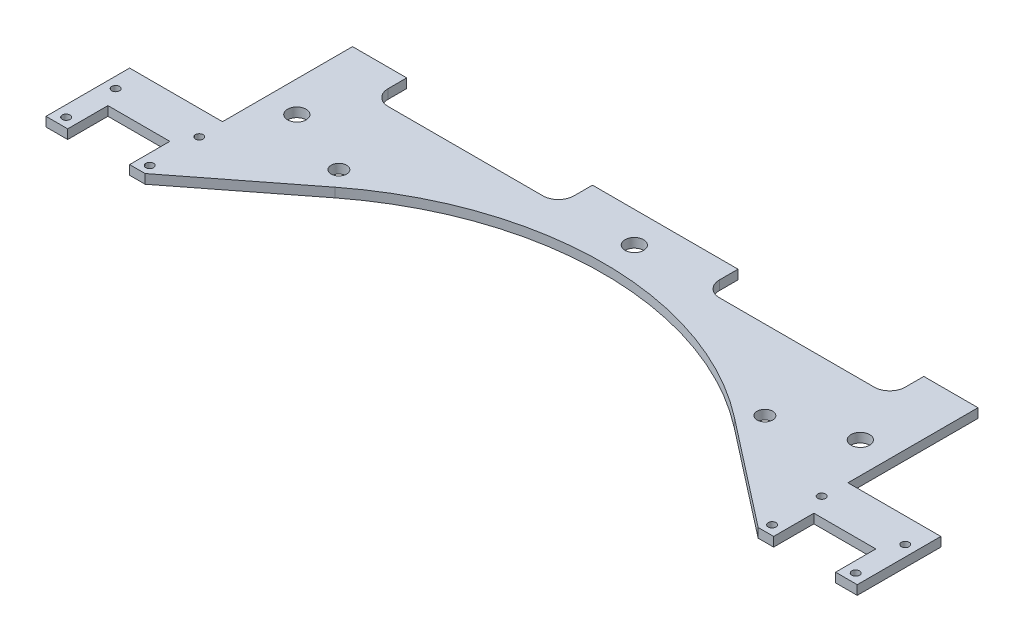
from build123d import *

# Parameters (mm, degrees)
ESQUISSE1_R      = 3
ESQUISSE1_R_2    = 1.25
ESQUISSE1_R_3    = 2.5
EXTRUSION1_DEPTH = 3


with BuildPart() as part:
    # Esquisse1 → Extrusion1 (new body)
    with BuildSketch(Plane(origin=(0, 0, 0), x_dir=(1, 0, 0), z_dir=(0, 1, 0))):
        with BuildLine():
            Line((-64.494367887, 52.858171056), (-99, 26))
            Line((-99, 26), (-104, 26))
            Line((-104, 26), (-104, 39))
            Line((-104, 39), (-124, 39))
            Line((-124, 39), (-124, 26))
            Line((-124, 26), (-131, 26))
            Line((-131, 26), (-131, 53))
            Line((-131, 53), (-101, 53))
            Line((-101, 53), (-101, 95))
            Line((-101, 95), (-83.5, 95))
            Line((-83.5, 95), (-83.5, 89))
            ThreePointArc((-83.5, 89), (-82.035533906, 85.464466094), (-78.5, 84))
            Line((-78.5, 84), (-28.5, 84))
            ThreePointArc((-28.5, 84), (-24.964466094, 85.464466094), (-23.5, 89))
            Line((-23.5, 89), (-23.5, 95))
            Line((-23.5, 95), (23.5, 95))
            Line((23.5, 95), (23.5, 89))
            ThreePointArc((23.5, 89), (24.964466094, 85.464466094), (28.5, 84))
            Line((28.5, 84), (78.5, 84))
            ThreePointArc((78.5, 84), (82.035533906, 85.464466094), (83.5, 89))
            Line((83.5, 89), (83.5, 95))
            Line((83.5, 95), (101, 95))
            Line((101, 95), (101, 53))
            Line((101, 53), (131, 53))
            Line((131, 53), (131, 26))
            Line((131, 26), (124, 26))
            Line((124, 26), (124, 39))
            Line((124, 39), (104, 39))
            Line((104, 39), (104, 26))
            Line((104, 26), (99, 26))
            Line((99, 26), (64.494367887, 52.858171056))
            ThreePointArc((64.494367887, 52.858171056), (0, 75), (-64.494367887, 52.858171056))
        make_face()
        with Locations((-91, 67)):
            Circle(ESQUISSE1_R, mode=Mode.SUBTRACT)
        with Locations((91, 67)):
            Circle(ESQUISSE1_R, mode=Mode.SUBTRACT)
        with Locations((-127.5, 45)):
            Circle(ESQUISSE1_R_2, mode=Mode.SUBTRACT)
        with Locations((-100.5, 45)):
            Circle(ESQUISSE1_R_2, mode=Mode.SUBTRACT)
        with Locations((-68.793992413, 58.382049127)):
            Circle(ESQUISSE1_R_3, mode=Mode.SUBTRACT)
        with Locations((68.793992413, 58.382049127)):
            Circle(ESQUISSE1_R_3, mode=Mode.SUBTRACT)
        with Locations((0, 85)):
            Circle(ESQUISSE1_R, mode=Mode.SUBTRACT)
        with Locations((-127.5, 29)):
            Circle(ESQUISSE1_R_2, mode=Mode.SUBTRACT)
        with Locations((-100.5, 29)):
            Circle(ESQUISSE1_R_2, mode=Mode.SUBTRACT)
        with Locations((100.5, 45)):
            Circle(ESQUISSE1_R_2, mode=Mode.SUBTRACT)
        with Locations((100.5, 29)):
            Circle(ESQUISSE1_R_2, mode=Mode.SUBTRACT)
        with Locations((127.5, 29)):
            Circle(ESQUISSE1_R_2, mode=Mode.SUBTRACT)
        with Locations((127.5, 45)):
            Circle(ESQUISSE1_R_2, mode=Mode.SUBTRACT)
    extrude(amount=EXTRUSION1_DEPTH)


solid = part.part
